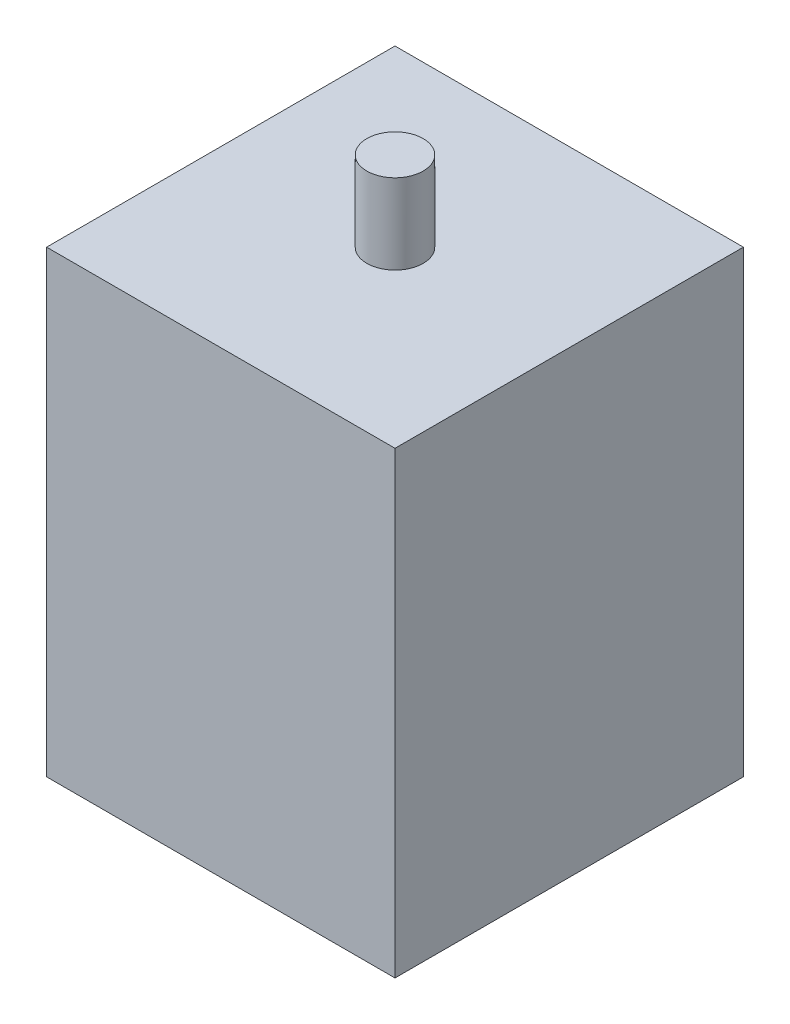
from build123d import *

# Parameters (mm, degrees)
SKETCH1_W           = 92.8
SKETCH1_H           = 92.8
BOSS_EXTRUDE1_DEPTH = 122.2
SKETCH2_R           = 7.5
BOSS_EXTRUDE2_DEPTH = 21.3


with BuildPart() as part:
    # Sketch1 → Boss-Extrude1 (new body)
    with BuildSketch(Plane(origin=(0, 0, 0), x_dir=(1, 0, 0), z_dir=(0, 1, 0))):
        with Locations((46.4, 46.4)):
            Rectangle(SKETCH1_W, SKETCH1_H)
    extrude(amount=BOSS_EXTRUDE1_DEPTH)

    # Sketch2 → Boss-Extrude2 (add)
    with BuildSketch(Plane(origin=(0, 122.2, 0), x_dir=(1, 0, 0), z_dir=(0, 1, 0))):
        with Locations((46.4, 46.4)):
            Circle(SKETCH2_R)
    extrude(amount=BOSS_EXTRUDE2_DEPTH)


solid = part.part
